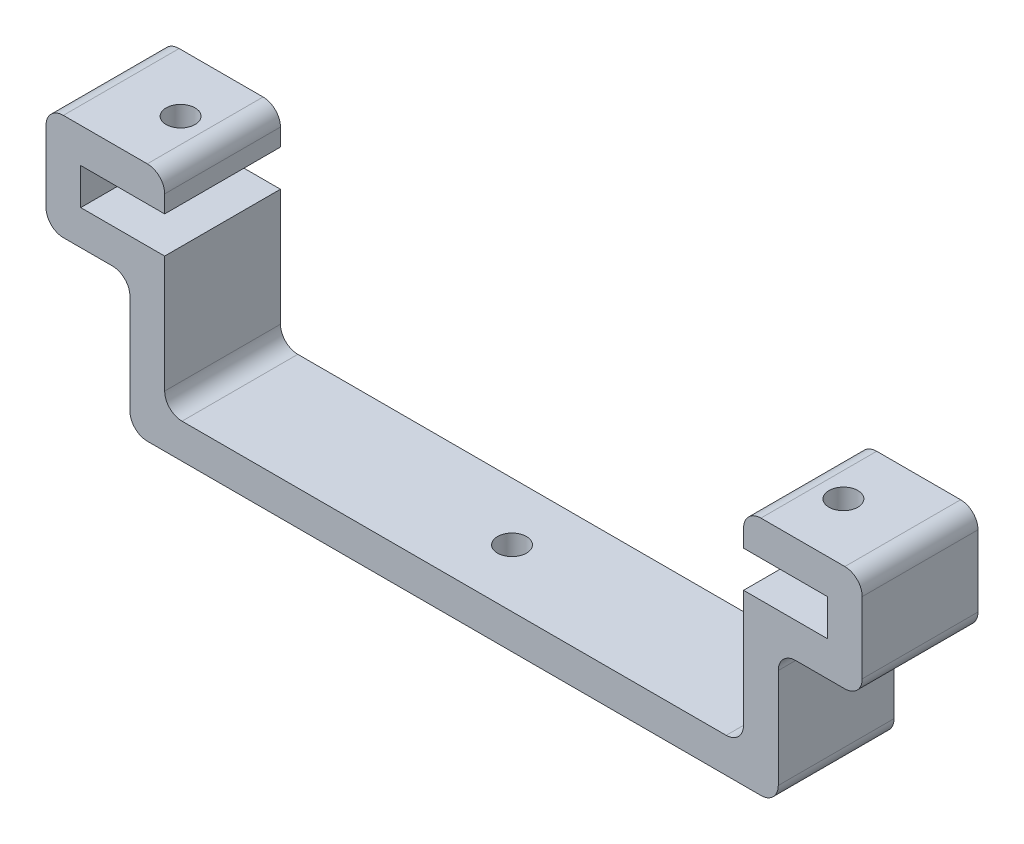
from build123d import *

# Parameters (mm, degrees)
BOSS_EXTRUDE1_DEPTH = 10
CUT_EXTRUDE2_REACH  = 22.75
SKETCH4_R           = 1.25
SKETCH5_R           = 1.25
CUT_EXTRUDE3_DEPTH  = 4
FILLET1_R           = 1.5


with BuildPart() as part:
    # Sketch1 → Boss-Extrude1 (new body)
    with BuildSketch(Plane.XY):
        Polygon((-32.25, 0), (-32.25, -3.15), (-25, -3.15), (-25, -14.75), (25, -14.75), (25, -3.15), (32.25, -3.15), (32.25, 0), (25, 0), (25, 3), (35.25, 3), (35.25, -6.15), (28, -6.15), (28, -17.75), (-28, -17.75), (-28, -6.15), (-35.25, -6.15), (-35.25, 3), (-25, 3), (-25, 0), align=None)
    extrude(amount=BOSS_EXTRUDE1_DEPTH)

    # Sketch4 → Cut-Extrude2 (cut, up to next)
    with BuildSketch(Plane(origin=(0, 3, 0), x_dir=(1, 0, 0), z_dir=(0, 1, 0)), mode=Mode.PRIVATE) as cut_extrude2_sk1:
        with Locations((-28.625, -5)):
            Circle(SKETCH4_R)
    cut_extrude2_tool1 = extrude(cut_extrude2_sk1.sketch, amount=-CUT_EXTRUDE2_REACH, mode=Mode.PRIVATE) & part.part
    add(cut_extrude2_tool1.solids().sort_by_distance((-28.625, 3, 5))[0], mode=Mode.SUBTRACT)
    # Sketch4 → Cut-Extrude2 (cut, up to next)
    with BuildSketch(Plane(origin=(0, 3, 0), x_dir=(1, 0, 0), z_dir=(0, 1, 0)), mode=Mode.PRIVATE) as cut_extrude2_sk2:
        with Locations((28.625, -5)):
            Circle(SKETCH4_R)
    cut_extrude2_tool2 = extrude(cut_extrude2_sk2.sketch, amount=-CUT_EXTRUDE2_REACH, mode=Mode.PRIVATE) & part.part
    add(cut_extrude2_tool2.solids().sort_by_distance((28.625, 3, 5))[0], mode=Mode.SUBTRACT)

    # Sketch5 → Cut-Extrude3 (cut, through all)
    with BuildSketch(Plane(origin=(0, -14.75, 0), x_dir=(1, 0, 0), z_dir=(0, 1, 0))):
        with Locations((0, -5)):
            Circle(SKETCH5_R)
    extrude(amount=-CUT_EXTRUDE3_DEPTH, mode=Mode.SUBTRACT)

    # Fillet1
    fillet1_edges = [part.edges().sort_by_distance(p)[0] for p in [
        (-25, -14.75, 5),
        (25, -14.75, 5),
        (25, 3, 5),
        (35.25, 3, 5),
        (35.25, -6.15, 5),
        (28, -6.15, 5),
        (28, -17.75, 5),
        (-28, -17.75, 5),
        (-28, -6.15, 5),
        (-35.25, -6.15, 5),
        (-35.25, 3, 5),
        (-25, 3, 5),
    ]]
    fillet(fillet1_edges, radius=FILLET1_R)


solid = part.part
